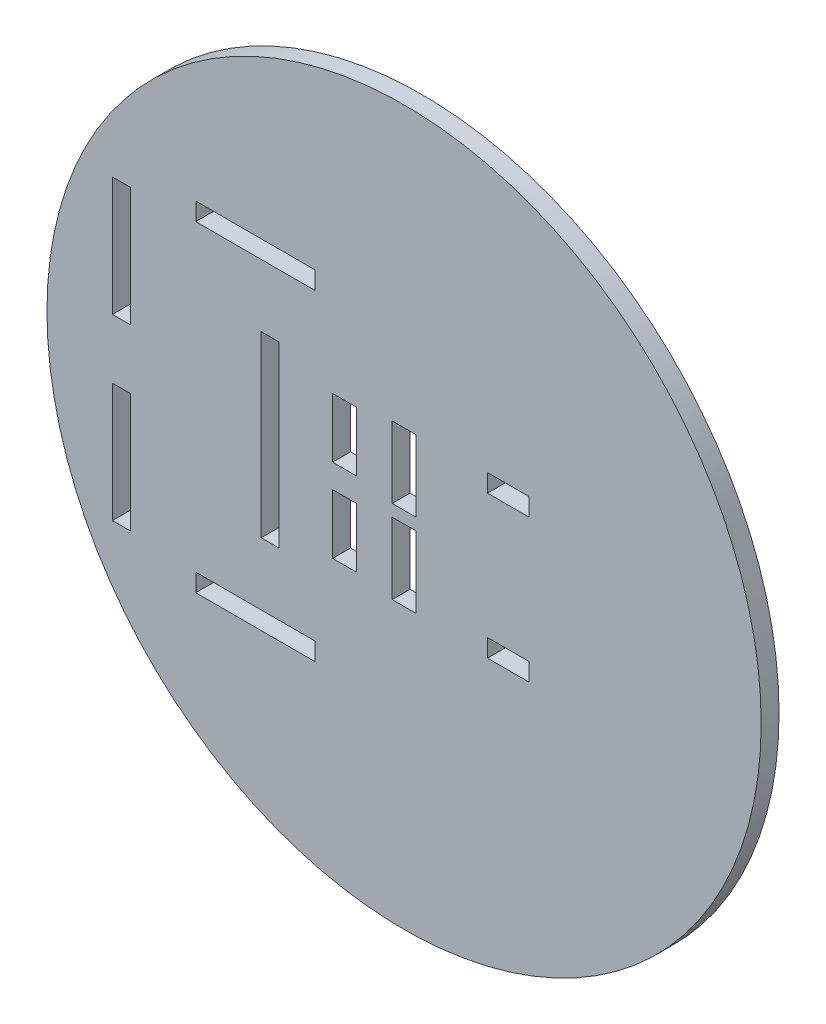
from build123d import *

# Parameters (mm, degrees)
SKETCH1_R           = 60
SKETCH1_W           = 20
SKETCH1_H           = 3
SKETCH1_W_2         = 3
SKETCH1_H_2         = 20
SKETCH1_H_3         = 30
SKETCH1_W_3         = 6.993462014
SKETCH1_W_4         = 4
SKETCH1_H_4         = 12
SKETCH1_H_5         = 10
BOSS_EXTRUDE1_DEPTH = 1.5


with BuildPart() as part:
    # Sketch1 → Boss-Extrude1 (new body, symmetric)
    with BuildSketch(Plane.XY):
        Circle(SKETCH1_R)
        with Locations((-25, -27)):
            Rectangle(SKETCH1_W, SKETCH1_H, mode=Mode.SUBTRACT)
        with Locations((-47.5, 15)):
            Rectangle(SKETCH1_W_2, SKETCH1_H_2, mode=Mode.SUBTRACT)
        with Locations((-47.5, -15)):
            Rectangle(SKETCH1_W_2, SKETCH1_H_2, mode=Mode.SUBTRACT)
        with Locations((-22.5, 0)):
            Rectangle(SKETCH1_W_2, SKETCH1_H_3, mode=Mode.SUBTRACT)
        with Locations((-25, 27)):
            Rectangle(SKETCH1_W, SKETCH1_H, mode=Mode.SUBTRACT)
        with Locations((17.516157806, -12)):
            Rectangle(SKETCH1_W_3, SKETCH1_H, mode=Mode.SUBTRACT)
        with Locations((17.516157806, 12)):
            Rectangle(SKETCH1_W_3, SKETCH1_H, mode=Mode.SUBTRACT)
        with Locations((0, 7)):
            Rectangle(SKETCH1_W_4, SKETCH1_H_4, mode=Mode.SUBTRACT)
        with Locations((0, -7)):
            Rectangle(SKETCH1_W_4, SKETCH1_H_4, mode=Mode.SUBTRACT)
        with Locations((-10, 7)):
            Rectangle(SKETCH1_W_4, SKETCH1_H_5, mode=Mode.SUBTRACT)
        with Locations((-10, -7)):
            Rectangle(SKETCH1_W_4, SKETCH1_H_5, mode=Mode.SUBTRACT)
    extrude(amount=BOSS_EXTRUDE1_DEPTH, both=True)


solid = part.part
